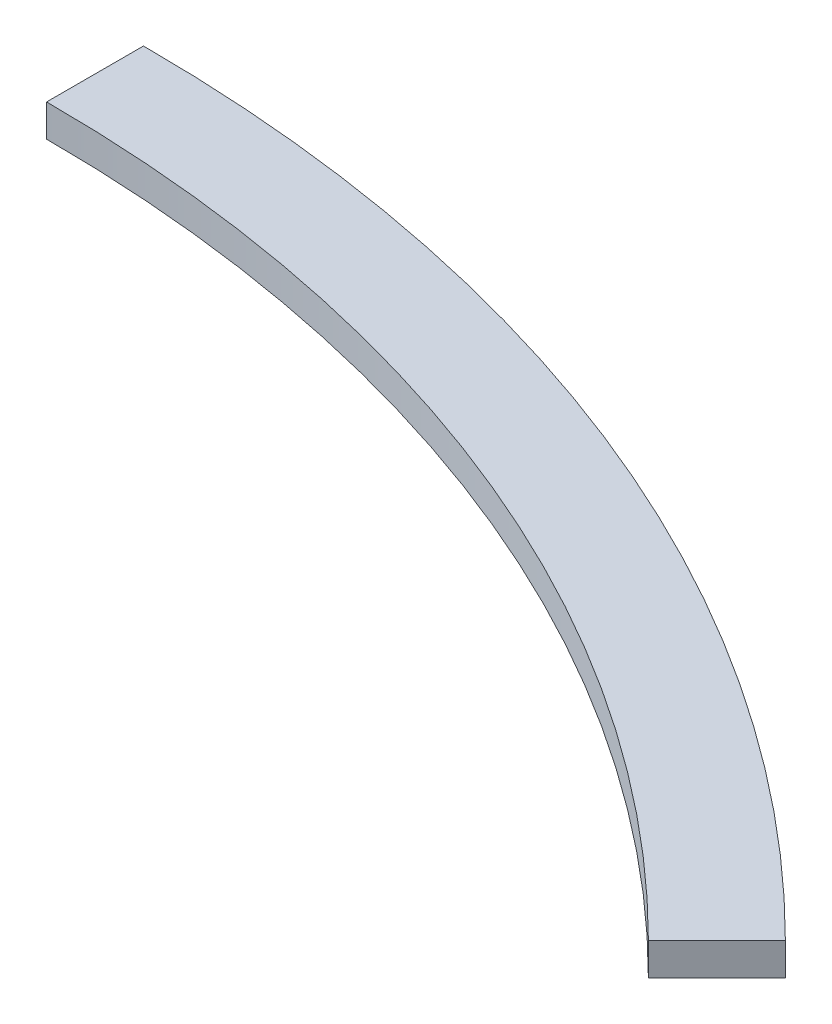
from build123d import *

# Parameters (mm, degrees)
BOSS_EXTRUDE1_DEPTH = 10


with BuildPart() as part:
    # Sketch1 → Boss-Extrude1 (new body)
    with BuildSketch(Plane(origin=(0, 0, 0), x_dir=(1, 0, 0), z_dir=(0, 1, 0))):
        with BuildLine():
            ThreePointArc((0, 480), (183.688047535, 443.462175605), (339.41125497, 339.41125497))
            Line((339.41125497, 339.41125497), (318.198051534, 318.198051534))
            ThreePointArc((318.198051534, 318.198051534), (172.207544564, 415.74578963), (0, 450))
            Line((0, 450), (0, 480))
        make_face()
    extrude(amount=BOSS_EXTRUDE1_DEPTH)


solid = part.part
